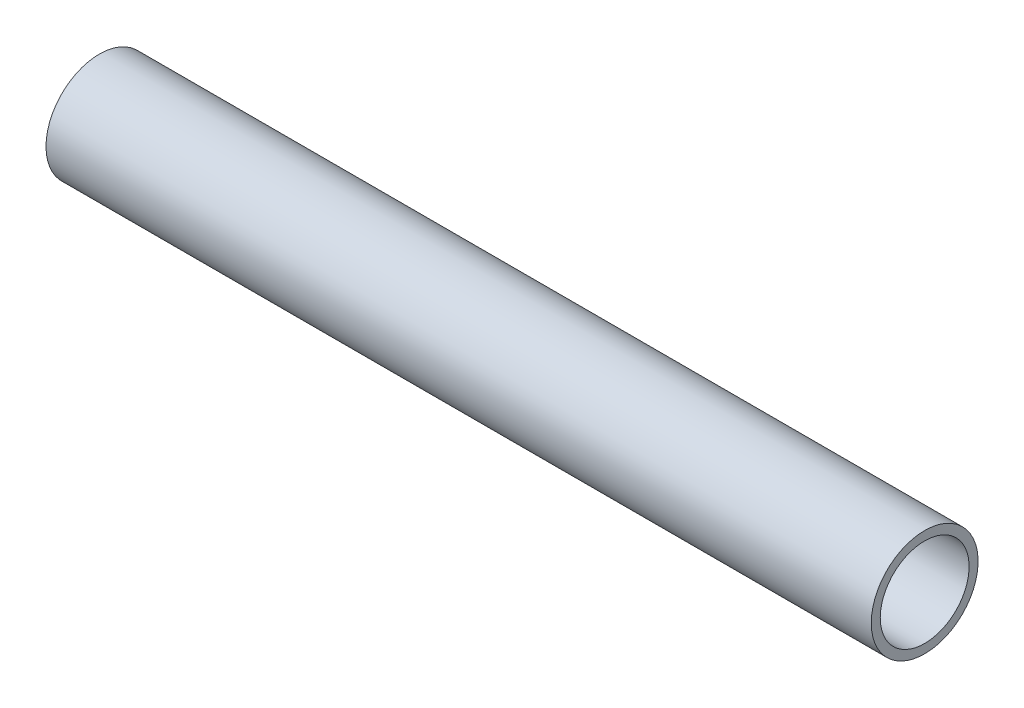
from build123d import *

# Parameters (mm, degrees)
SKETCH11_R              = 6.35
SKETCH11_R_2            = 5.2832
PIPE_0_5_SCH_40_1_DEPTH = 98.098891053


with BuildPart() as part:
    # Sketch11 → Pipe 0.5 SCH 40(1) (new body)
    with BuildSketch(Plane(origin=(123.30164532, 668.699839019, 0), x_dir=(0, -1, 0), z_dir=(-1, 0, 0))):
        Circle(SKETCH11_R)
        Circle(SKETCH11_R_2, mode=Mode.SUBTRACT)
    extrude(amount=PIPE_0_5_SCH_40_1_DEPTH)


solid = part.part
